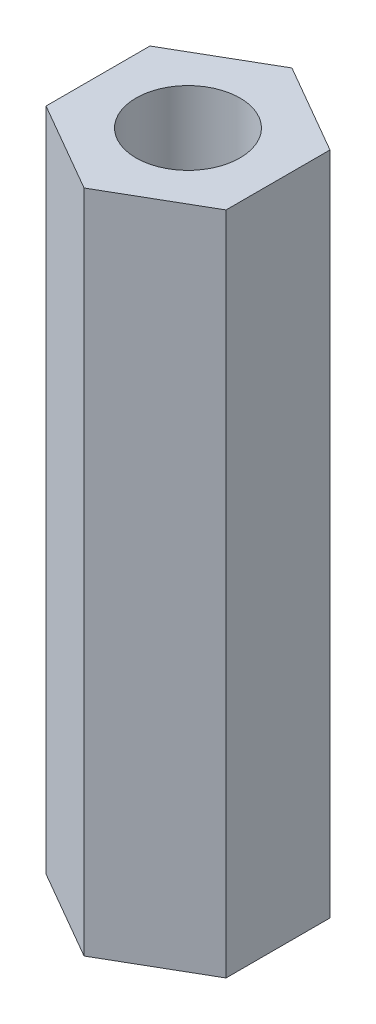
from build123d import *

# Parameters (mm, degrees)
ESQUISSE1_R      = 2.5
EXTRUSION1_DEPTH = 32


with BuildPart() as part:
    # Esquisse1 → Extrusion1 (new body)
    with BuildSketch(Plane(origin=(0, 0, 0), x_dir=(1, 0, 0), z_dir=(0, 1, 0))):
        Polygon((0, 5), (-4.330127019, 2.5), (-4.330127019, -2.5), (0, -5), (4.330127019, -2.5), (4.330127019, 2.5), align=None)
        Circle(ESQUISSE1_R, mode=Mode.SUBTRACT)
    extrude(amount=EXTRUSION1_DEPTH)


solid = part.part
